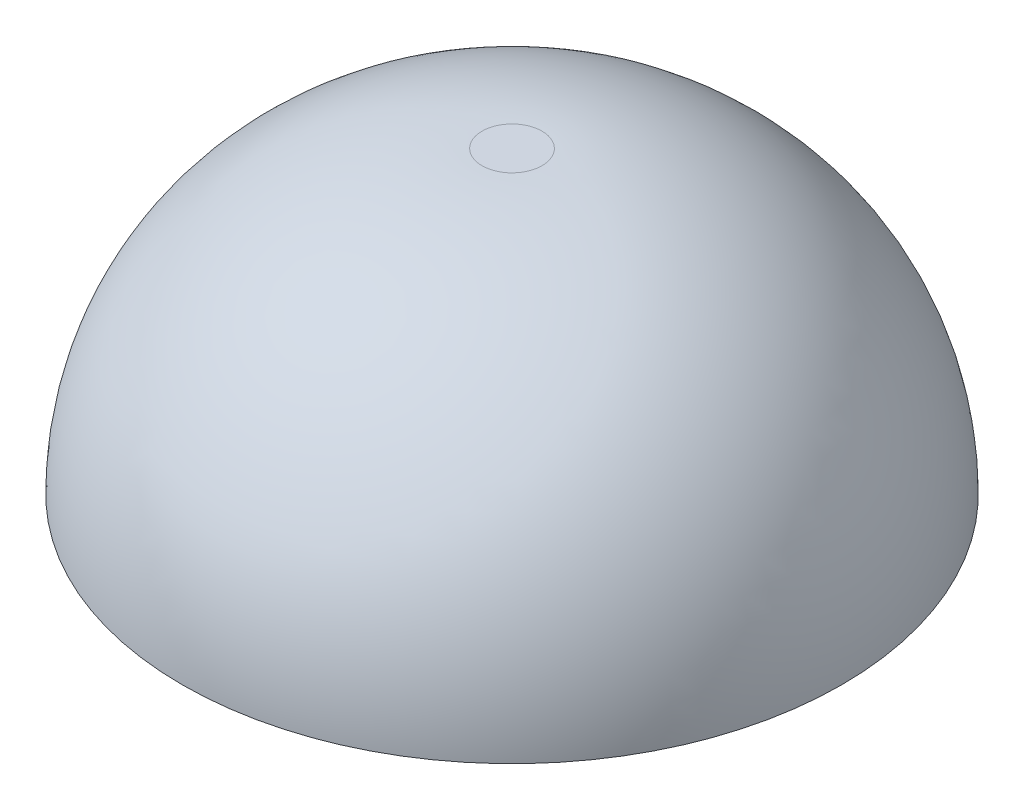
from build123d import *


with BuildPart() as part:
    # Sketch1 → Revolve1 (revolve)
    with BuildSketch(Plane(origin=(0, 0, 0), x_dir=(0, 0, -1), z_dir=(1, 0, 0))):
        with BuildLine():
            Line((0, 0), (5.588, 0))
            ThreePointArc((5.588, 0), (4.100102448, 3.592102448), (0.508, 5.08))
            Line((0.508, 5.08), (0, 5.08))
            Line((0, 5.08), (0, 0))
        make_face()
    revolve(axis=Axis((0, 0, 0), (0, 1, 0)))


solid = part.part
